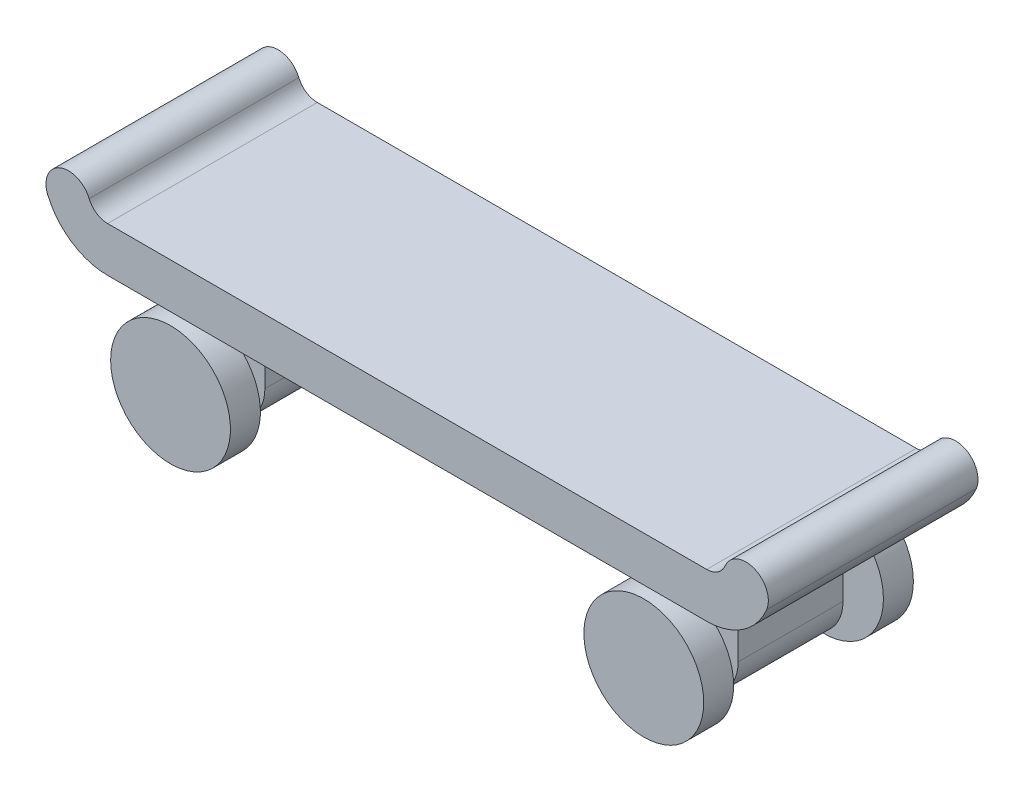
from build123d import *

# Parameters (mm, degrees)
BOSS_EXTRUDE1_DEPTH   = 7
SKETCH2_R             = 1.75
BOSS_EXTRUDE2_DEPTH   = 3.5
SKETCH3_R             = 1.15
BOSS_EXTRUDE3_DEPTH   = 5
BOSS_EXTRUDE3_2_DEPTH = 5
SKETCH4_R             = 4
BOSS_EXTRUDE4_DEPTH   = 2


with BuildPart() as part:
    # Sketch1 → Boss-Extrude1 (new body, symmetric)
    with BuildSketch(Plane.XY):
        with BuildLine():
            Line((-20, 0), (20, 0))
            ThreePointArc((20, 0), (22.40370085, 0.727782058), (24, 2.666666667))
            ThreePointArc((24, 2.666666667), (23.192307692, 4.628205128), (21.230769231, 3.820512821))
            ThreePointArc((21.230769231, 3.820512821), (20.739600262, 3.223932941), (20, 3))
            Line((20, 3), (-20, 3))
            ThreePointArc((-20, 3), (-20.739600262, 3.223932941), (-21.230769231, 3.820512821))
            ThreePointArc((-21.230769231, 3.820512821), (-23.192307692, 4.628205128), (-24, 2.666666667))
            ThreePointArc((-24, 2.666666667), (-22.40370085, 0.727782058), (-20, 0))
        make_face()
    extrude(amount=BOSS_EXTRUDE1_DEPTH, both=True)

    # Sketch2 → Boss-Extrude2 (add, symmetric)
    with BuildSketch(Plane.XY):
        with BuildLine():
            Line((18.6, 0), (18.6, -4.8))
            ThreePointArc((18.6, -4.8), (15.8, -7.6), (13, -4.8))
            Line((13, -4.8), (13, 0))
            Line((13, 0), (18.6, 0))
        make_face()
        with Locations((15.8, -4.8)):
            Circle(SKETCH2_R, mode=Mode.SUBTRACT)
        with BuildLine():
            Line((-13, 0), (-18.6, 0))
            Line((-18.6, 0), (-18.6, -4.8))
            ThreePointArc((-18.6, -4.8), (-15.8, -7.6), (-13, -4.8))
            Line((-13, -4.8), (-13, 0))
        make_face()
        with Locations(Location((-15.8, -4.8, 0), (0, 0, 180))):  # turned: the seam where the file's is
            Circle(SKETCH2_R, mode=Mode.SUBTRACT)
    extrude(amount=BOSS_EXTRUDE2_DEPTH, both=True)


with BuildPart() as body_2:
    # Sketch3 → Boss-Extrude3 (new body, symmetric)
    with BuildSketch(Plane.XY):
        with Locations((15.8, -4.8)):
            Circle(SKETCH3_R)
    extrude(amount=BOSS_EXTRUDE3_DEPTH, both=True)



with BuildPart() as body_3:
    # Sketch3 → Boss-Extrude3 2 (new body, symmetric)
    with BuildSketch(Plane.XY):
        with Locations(Location((-15.8, -4.8, 0), (0, 0, 180))):  # turned: the seam where the file's is
            Circle(SKETCH3_R)
    extrude(amount=BOSS_EXTRUDE3_2_DEPTH, both=True)


with BuildPart() as body_2_1:
    add(body_2.part)

    add(body_3.part)  # Boss-Extrude4 merges body 3
    # Sketch4 → Boss-Extrude4 (add)
    with BuildSketch(Plane.XY.offset(5)):
        with Locations((15.8, -4.8)):
            Circle(SKETCH4_R)
        with Locations(Location((-15.8, -4.8, 0), (0, 0, 180))):  # turned: the seam where the file's is
            Circle(SKETCH4_R)
    boss_extrude4 = extrude(amount=BOSS_EXTRUDE4_DEPTH)

    # Mirror1: Boss-Extrude4 across plane
    add(boss_extrude4.mirror(Plane.XY))


solid = Compound([part.part, body_2_1.part])
